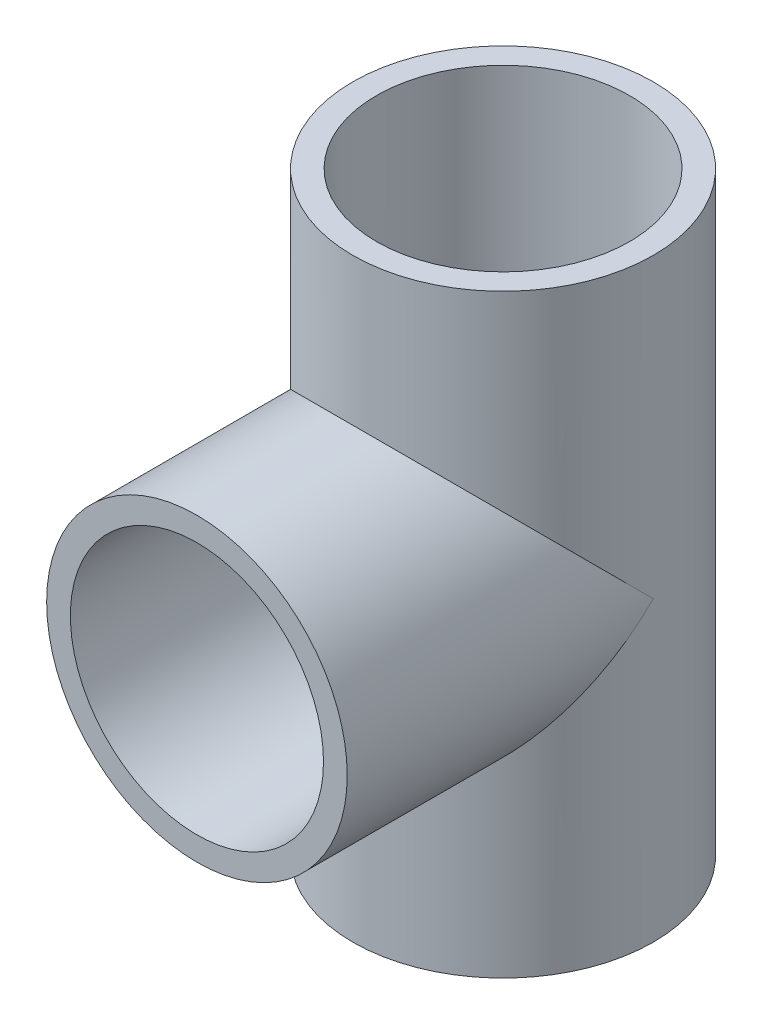
from build123d import *

# Parameters (mm, degrees)
SKETCH_1_R          = 19
SKETCH_1_R_2        = 16
EXTRUDE_1_DEPTH     = 75.2
SKETCH_2_R          = 19
SKETCH_2_R_2        = 16
EXTRUDE_2_DEPTH     = 38.7
SKETCH_3_R          = 16
CUT_EXTRUDE_1_DEPTH = 76.2000001
CUT_EXTRUDE_2_REACH = 59.7
SKETCH_4_R          = 16


with BuildPart() as part:
    # 草图1 → 凸台-拉伸1 (new body)
    with BuildSketch(Plane(origin=(0, 0, 0), x_dir=(1, 0, 0), z_dir=(0, 1, 0))):
        Circle(SKETCH_1_R)
        Circle(SKETCH_1_R_2, mode=Mode.SUBTRACT)
    extrude(amount=EXTRUDE_1_DEPTH)

    # 草图2 → 凸台-拉伸2 (add)
    with BuildSketch(Plane.XY):
        with Locations((0, 37.6)):
            Circle(SKETCH_2_R)
        with Locations((0, 37.6)):
            Circle(SKETCH_2_R_2, mode=Mode.SUBTRACT)
    extrude(amount=EXTRUDE_2_DEPTH)

    # 草图3 → 切除-拉伸1 (cut, through all)
    with BuildSketch(Plane(origin=(0, 75.2, 0), x_dir=(1, 0, 0), z_dir=(0, 1, 0))):
        Circle(SKETCH_3_R)
    extrude(amount=-CUT_EXTRUDE_1_DEPTH, mode=Mode.SUBTRACT)

    # 草图4 → 切除-拉伸2 (cut, up to next)
    with BuildSketch(Plane.XY.offset(38.7), mode=Mode.PRIVATE) as cut_extrude_2_sk1:
        with Locations((0, 37.6)):
            Circle(SKETCH_4_R)
    cut_extrude_2_tool1 = extrude(cut_extrude_2_sk1.sketch, amount=-CUT_EXTRUDE_2_REACH, mode=Mode.PRIVATE) & part.part
    add(cut_extrude_2_tool1.solids().sort_by_distance((0, 37.6, 38.7))[0], mode=Mode.SUBTRACT)


solid = part.part
